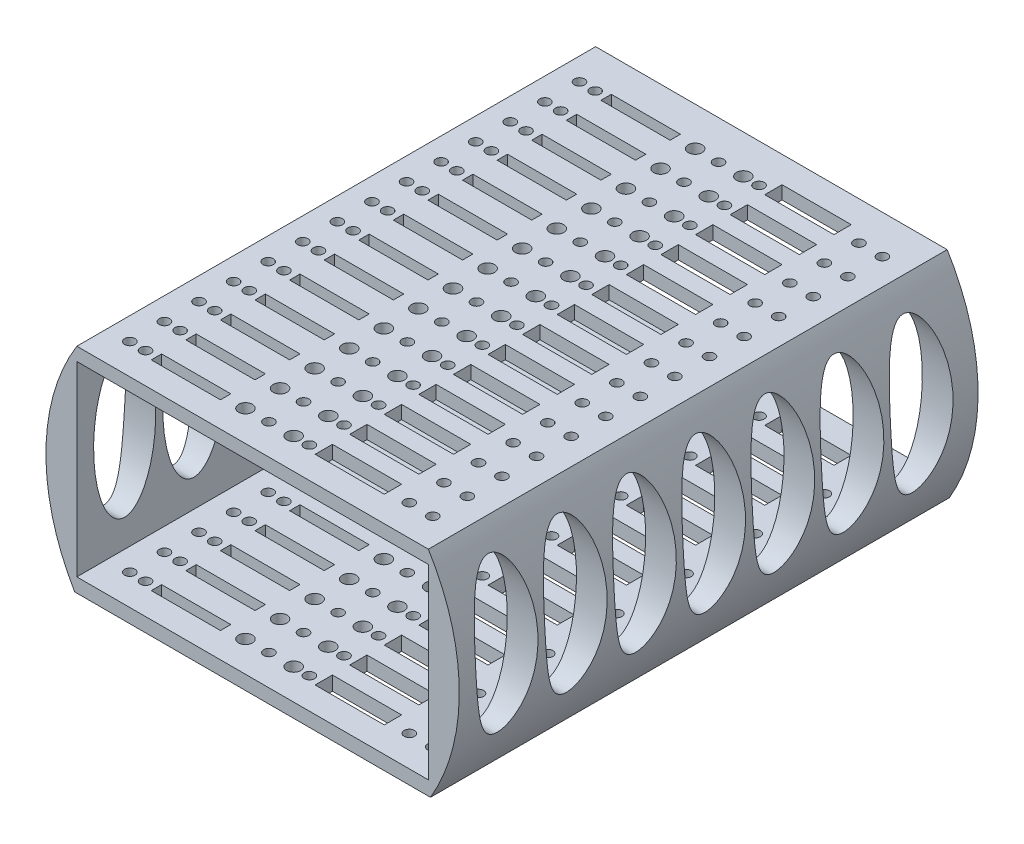
from build123d import *

# Parameters (mm, degrees)
SKETCH_4_R               = 59.75
EXTRUDE_1_DEPTH          = 150
CUT_EXTRUDE_3_DEPTH      = 173.163076762
CUT_EXTRUDE_3_DEPTH_BACK = 173.163076762
CUT_EXTRUDE_4_DEPTH      = 173.163076762
SKETCH_5_4_W             = 101.636218728
SKETCH_5_4_H             = 53.936134462
CUT_EXTRUDE_5_DEPTH      = 150
CUT_EXTRUDE_6_DEPTH      = 189.978541292
CUT_EXTRUDE_6_DEPTH_BACK = 189.978541292
SKETCH_6_RX              = 21.698109429
SKETCH_6_RY              = 8.98486276
CUT_EXTRUDE_7_DEPTH      = 173.897395707
CUT_EXTRUDE_7_DEPTH_BACK = 173.897395707
SKETCH_8_R               = 1.5
SKETCH_8_R_2             = 2
SKETCH_8_W               = 20
SKETCH_8_H               = 3
SKETCH_8_H_2             = 5


with BuildPart() as part:
    # 草图4 → 凸台-拉伸1 (new body)
    with BuildSketch(Plane.XY):
        Circle(SKETCH_4_R)
    extrude(amount=EXTRUDE_1_DEPTH)

    # 草图5 → 切除-拉伸3 (cut, two sides: drawn at the far end of the back side and taken through both)
    with BuildSketch(Plane.XY.offset(150).offset(-CUT_EXTRUDE_3_DEPTH_BACK)):
        with BuildLine():
            Line((-50.818109364, 31.425821559), (50.818109364, 31.425821559))
            ThreePointArc((50.818109364, 31.425821559), (0, 59.75), (-50.818109364, 31.425821559))
        make_face()
    extrude(amount=CUT_EXTRUDE_3_DEPTH + CUT_EXTRUDE_3_DEPTH_BACK, mode=Mode.SUBTRACT)

    # 草图5<3> → 切除-拉伸4 (cut, through all)
    with BuildSketch(Plane.XY.offset(150)):
        with BuildLine():
            Line((51.433486615, -30.408205384), (-51.433486615, -30.408205384))
            ThreePointArc((-51.433486615, -30.408205384), (0, -59.75), (51.433486615, -30.408205384))
        make_face()
    extrude(amount=-CUT_EXTRUDE_4_DEPTH, mode=Mode.SUBTRACT)

    # 草图5<4> → 切除-拉伸5 (cut)
    with BuildSketch(Plane.XY.offset(150)):
        with Locations((0, 0.631501799)):
            Rectangle(SKETCH_5_4_W, SKETCH_5_4_H)
    extrude(amount=-CUT_EXTRUDE_5_DEPTH, mode=Mode.SUBTRACT)

    # 草图6 → 切除-拉伸6 (cut, two sides: drawn at the far end of the back side and taken through both)
    with BuildSketch(Plane.ZY.offset(-50.818109364).offset(-CUT_EXTRUDE_6_DEPTH_BACK)):
        with Locations(Location((16.164235384, 3.394943947), (0, 0, -90))):
            Ellipse(SKETCH_6_RX, SKETCH_6_RY)
        with Locations(Location((36.164235384, 3.394943947), (0, 0, -90))):
            Ellipse(SKETCH_6_RX, SKETCH_6_RY)
        with Locations(Location((56.164235384, 3.394943947), (0, 0, -90))):
            Ellipse(SKETCH_6_RX, SKETCH_6_RY)
        with Locations(Location((76.164235384, 3.394943947), (0, 0, -90))):
            Ellipse(SKETCH_6_RX, SKETCH_6_RY)
        with Locations(Location((96.164235384, 3.394943947), (0, 0, -90))):
            Ellipse(SKETCH_6_RX, SKETCH_6_RY)
        with Locations(Location((116.164235384, 3.394943947), (0, 0, -90))):
            Ellipse(SKETCH_6_RX, SKETCH_6_RY)
        with Locations(Location((136.164235384, 3.394943947), (0, 0, -90))):
            Ellipse(SKETCH_6_RX, SKETCH_6_RY)
    extrude(amount=CUT_EXTRUDE_6_DEPTH + CUT_EXTRUDE_6_DEPTH_BACK, mode=Mode.SUBTRACT)

    # 草图8 → 切除-拉伸7 (cut, two sides: drawn at the far end of the back side and taken through both)
    with BuildSketch(Plane(origin=(0, 31.425821559, 0), x_dir=(1, 0, 0), z_dir=(0, 1, 0)).offset(-CUT_EXTRUDE_7_DEPTH_BACK)):
        with Locations((-44.320254624, -11.168496968)):
            Circle(SKETCH_8_R)
        with Locations((-39.784391217, -11.168496968)):
            Circle(SKETCH_8_R)
        with Locations((-10.889179801, -11.168496968)):
            Circle(SKETCH_8_R_2)
        with Locations((-4.106963021, -11.168496968)):
            Circle(SKETCH_8_R)
        with Locations((3.002209794, -11.117617248)):
            Circle(SKETCH_8_R_2)
        with Locations((7.538073201, -11.117617248)):
            Circle(SKETCH_8_R)
        with Locations((36.433284617, -11.117617248)):
            Circle(SKETCH_8_R)
        with Locations((43.215501397, -11.117617248)):
            Circle(SKETCH_8_R)
        with Locations((-44.320254624, -21.168496968)):
            Circle(SKETCH_8_R)
        with Locations((-39.784391217, -21.168496968)):
            Circle(SKETCH_8_R)
        with Locations((-10.889179801, -21.168496968)):
            Circle(SKETCH_8_R_2)
        with Locations((-4.106963021, -21.168496968)):
            Circle(SKETCH_8_R)
        with Locations((3.002209794, -21.117617248)):
            Circle(SKETCH_8_R_2)
        with Locations((7.538073201, -21.117617248)):
            Circle(SKETCH_8_R)
        with Locations((36.433284617, -21.117617248)):
            Circle(SKETCH_8_R)
        with Locations((43.215501397, -21.117617248)):
            Circle(SKETCH_8_R)
        with Locations((-44.320254624, -31.168496968)):
            Circle(SKETCH_8_R)
        with Locations((-39.784391217, -31.168496968)):
            Circle(SKETCH_8_R)
        with Locations((-10.889179801, -31.168496968)):
            Circle(SKETCH_8_R_2)
        with Locations((-4.106963021, -31.168496968)):
            Circle(SKETCH_8_R)
        with Locations((3.002209794, -31.117617248)):
            Circle(SKETCH_8_R_2)
        with Locations((7.538073201, -31.117617248)):
            Circle(SKETCH_8_R)
        with Locations((36.433284617, -31.117617248)):
            Circle(SKETCH_8_R)
        with Locations((43.215501397, -31.117617248)):
            Circle(SKETCH_8_R)
        with Locations((-44.320254624, -41.168496968)):
            Circle(SKETCH_8_R)
        with Locations((-39.784391217, -41.168496968)):
            Circle(SKETCH_8_R)
        with Locations((-10.889179801, -41.168496968)):
            Circle(SKETCH_8_R_2)
        with Locations((-4.106963021, -41.168496968)):
            Circle(SKETCH_8_R)
        with Locations((3.002209794, -41.117617248)):
            Circle(SKETCH_8_R_2)
        with Locations((7.538073201, -41.117617248)):
            Circle(SKETCH_8_R)
        with Locations((36.433284617, -41.117617248)):
            Circle(SKETCH_8_R)
        with Locations((43.215501397, -41.117617248)):
            Circle(SKETCH_8_R)
        with Locations((-44.320254624, -51.168496968)):
            Circle(SKETCH_8_R)
        with Locations((-39.784391217, -51.168496968)):
            Circle(SKETCH_8_R)
        with Locations((-10.889179801, -51.168496968)):
            Circle(SKETCH_8_R_2)
        with Locations((-4.106963021, -51.168496968)):
            Circle(SKETCH_8_R)
        with Locations((3.002209794, -51.117617248)):
            Circle(SKETCH_8_R_2)
        with Locations((7.538073201, -51.117617248)):
            Circle(SKETCH_8_R)
        with Locations((36.433284617, -51.117617248)):
            Circle(SKETCH_8_R)
        with Locations((43.215501397, -51.117617248)):
            Circle(SKETCH_8_R)
        with Locations((-44.320254624, -61.168496968)):
            Circle(SKETCH_8_R)
        with Locations((-39.784391217, -61.168496968)):
            Circle(SKETCH_8_R)
        with Locations((-10.889179801, -61.168496968)):
            Circle(SKETCH_8_R_2)
        with Locations((-4.106963021, -61.168496968)):
            Circle(SKETCH_8_R)
        with Locations((3.002209794, -61.117617248)):
            Circle(SKETCH_8_R_2)
        with Locations((7.538073201, -61.117617248)):
            Circle(SKETCH_8_R)
        with Locations((36.433284617, -61.117617248)):
            Circle(SKETCH_8_R)
        with Locations((43.215501397, -61.117617248)):
            Circle(SKETCH_8_R)
        with Locations((-44.320254624, -71.168496968)):
            Circle(SKETCH_8_R)
        with Locations((-39.784391217, -71.168496968)):
            Circle(SKETCH_8_R)
        with Locations((-10.889179801, -71.168496968)):
            Circle(SKETCH_8_R_2)
        with Locations((-4.106963021, -71.168496968)):
            Circle(SKETCH_8_R)
        with Locations((3.002209794, -71.117617248)):
            Circle(SKETCH_8_R_2)
        with Locations((7.538073201, -71.117617248)):
            Circle(SKETCH_8_R)
        with Locations((36.433284617, -71.117617248)):
            Circle(SKETCH_8_R)
        with Locations((43.215501397, -71.117617248)):
            Circle(SKETCH_8_R)
        with Locations((-44.320254624, -81.168496968)):
            Circle(SKETCH_8_R)
        with Locations((-39.784391217, -81.168496968)):
            Circle(SKETCH_8_R)
        with Locations((-10.889179801, -81.168496968)):
            Circle(SKETCH_8_R_2)
        with Locations((-4.106963021, -81.168496968)):
            Circle(SKETCH_8_R)
        with Locations((3.002209794, -81.117617248)):
            Circle(SKETCH_8_R_2)
        with Locations((7.538073201, -81.117617248)):
            Circle(SKETCH_8_R)
        with Locations((36.433284617, -81.117617248)):
            Circle(SKETCH_8_R)
        with Locations((43.215501397, -81.117617248)):
            Circle(SKETCH_8_R)
        with Locations((-44.320254624, -91.168496968)):
            Circle(SKETCH_8_R)
        with Locations((-39.784391217, -91.168496968)):
            Circle(SKETCH_8_R)
        with Locations((-10.889179801, -91.168496968)):
            Circle(SKETCH_8_R_2)
        with Locations((-4.106963021, -91.168496968)):
            Circle(SKETCH_8_R)
        with Locations((3.002209794, -91.117617248)):
            Circle(SKETCH_8_R_2)
        with Locations((7.538073201, -91.117617248)):
            Circle(SKETCH_8_R)
        with Locations((36.433284617, -91.117617248)):
            Circle(SKETCH_8_R)
        with Locations((43.215501397, -91.117617248)):
            Circle(SKETCH_8_R)
        with Locations((-44.320254624, -101.168496968)):
            Circle(SKETCH_8_R)
        with Locations((-39.784391217, -101.168496968)):
            Circle(SKETCH_8_R)
        with Locations((-10.889179801, -101.168496968)):
            Circle(SKETCH_8_R_2)
        with Locations((-4.106963021, -101.168496968)):
            Circle(SKETCH_8_R)
        with Locations((3.002209794, -101.117617248)):
            Circle(SKETCH_8_R_2)
        with Locations((7.538073201, -101.117617248)):
            Circle(SKETCH_8_R)
        with Locations((36.433284617, -101.117617248)):
            Circle(SKETCH_8_R)
        with Locations((43.215501397, -101.117617248)):
            Circle(SKETCH_8_R)
        with Locations((-44.320254624, -111.168496968)):
            Circle(SKETCH_8_R)
        with Locations((-39.784391217, -111.168496968)):
            Circle(SKETCH_8_R)
        with Locations((-10.889179801, -111.168496968)):
            Circle(SKETCH_8_R_2)
        with Locations((-4.106963021, -111.168496968)):
            Circle(SKETCH_8_R)
        with Locations((3.002209794, -111.117617248)):
            Circle(SKETCH_8_R_2)
        with Locations((7.538073201, -111.117617248)):
            Circle(SKETCH_8_R)
        with Locations((36.433284617, -111.117617248)):
            Circle(SKETCH_8_R)
        with Locations((43.215501397, -111.117617248)):
            Circle(SKETCH_8_R)
        with Locations((-44.320254624, -121.168496968)):
            Circle(SKETCH_8_R)
        with Locations((-39.784391217, -121.168496968)):
            Circle(SKETCH_8_R)
        with Locations((-10.889179801, -121.168496968)):
            Circle(SKETCH_8_R_2)
        with Locations((-4.106963021, -121.168496968)):
            Circle(SKETCH_8_R)
        with Locations((3.002209794, -121.117617248)):
            Circle(SKETCH_8_R_2)
        with Locations((7.538073201, -121.117617248)):
            Circle(SKETCH_8_R)
        with Locations((36.433284617, -121.117617248)):
            Circle(SKETCH_8_R)
        with Locations((43.215501397, -121.117617248)):
            Circle(SKETCH_8_R)
        with Locations((-44.320254624, -131.168496968)):
            Circle(SKETCH_8_R)
        with Locations((-39.784391217, -131.168496968)):
            Circle(SKETCH_8_R)
        with Locations((-10.889179801, -131.168496968)):
            Circle(SKETCH_8_R_2)
        with Locations((-4.106963021, -131.168496968)):
            Circle(SKETCH_8_R)
        with Locations((3.002209794, -131.117617248)):
            Circle(SKETCH_8_R_2)
        with Locations((7.538073201, -131.117617248)):
            Circle(SKETCH_8_R)
        with Locations((36.433284617, -131.117617248)):
            Circle(SKETCH_8_R)
        with Locations((43.215501397, -131.117617248)):
            Circle(SKETCH_8_R)
        with Locations((-44.320254624, -141.168496968)):
            Circle(SKETCH_8_R)
        with Locations((-39.784391217, -141.168496968)):
            Circle(SKETCH_8_R)
        with Locations((-10.889179801, -141.168496968)):
            Circle(SKETCH_8_R_2)
        with Locations((-4.106963021, -141.168496968)):
            Circle(SKETCH_8_R)
        with Locations((3.002209794, -141.117617248)):
            Circle(SKETCH_8_R_2)
        with Locations((7.538073201, -141.117617248)):
            Circle(SKETCH_8_R)
        with Locations((36.433284617, -141.117617248)):
            Circle(SKETCH_8_R)
        with Locations((43.215501397, -141.117617248)):
            Circle(SKETCH_8_R)
        with Locations((-26.630103352, -11.168496968)):
            Rectangle(SKETCH_8_W, SKETCH_8_H)
        with Locations((20.692361066, -10.117617248)):
            Rectangle(SKETCH_8_W, SKETCH_8_H_2)
        with Locations((-26.630103352, -21.168496968)):
            Rectangle(SKETCH_8_W, SKETCH_8_H)
        with Locations((20.692361066, -20.117617248)):
            Rectangle(SKETCH_8_W, SKETCH_8_H_2)
        with Locations((-26.630103352, -31.168496968)):
            Rectangle(SKETCH_8_W, SKETCH_8_H)
        with Locations((20.692361066, -30.117617248)):
            Rectangle(SKETCH_8_W, SKETCH_8_H_2)
        with Locations((-26.630103352, -41.168496968)):
            Rectangle(SKETCH_8_W, SKETCH_8_H)
        with Locations((20.692361066, -40.117617248)):
            Rectangle(SKETCH_8_W, SKETCH_8_H_2)
        with Locations((-26.630103352, -51.168496968)):
            Rectangle(SKETCH_8_W, SKETCH_8_H)
        with Locations((20.692361066, -50.117617248)):
            Rectangle(SKETCH_8_W, SKETCH_8_H_2)
        with Locations((-26.630103352, -61.168496968)):
            Rectangle(SKETCH_8_W, SKETCH_8_H)
        with Locations((20.692361066, -60.117617248)):
            Rectangle(SKETCH_8_W, SKETCH_8_H_2)
        with Locations((-26.630103352, -71.168496968)):
            Rectangle(SKETCH_8_W, SKETCH_8_H)
        with Locations((20.692361066, -70.117617248)):
            Rectangle(SKETCH_8_W, SKETCH_8_H_2)
        with Locations((-26.630103352, -81.168496968)):
            Rectangle(SKETCH_8_W, SKETCH_8_H)
        with Locations((20.692361066, -80.117617248)):
            Rectangle(SKETCH_8_W, SKETCH_8_H_2)
        with Locations((-26.630103352, -91.168496968)):
            Rectangle(SKETCH_8_W, SKETCH_8_H)
        with Locations((20.692361066, -90.117617248)):
            Rectangle(SKETCH_8_W, SKETCH_8_H_2)
        with Locations((-26.630103352, -101.168496968)):
            Rectangle(SKETCH_8_W, SKETCH_8_H)
        with Locations((20.692361066, -100.117617248)):
            Rectangle(SKETCH_8_W, SKETCH_8_H_2)
        with Locations((-26.630103352, -111.168496968)):
            Rectangle(SKETCH_8_W, SKETCH_8_H)
        with Locations((20.692361066, -110.117617248)):
            Rectangle(SKETCH_8_W, SKETCH_8_H_2)
        with Locations((-26.630103352, -121.168496968)):
            Rectangle(SKETCH_8_W, SKETCH_8_H)
        with Locations((20.692361066, -120.117617248)):
            Rectangle(SKETCH_8_W, SKETCH_8_H_2)
        with Locations((-26.630103352, -131.168496968)):
            Rectangle(SKETCH_8_W, SKETCH_8_H)
        with Locations((20.692361066, -130.117617248)):
            Rectangle(SKETCH_8_W, SKETCH_8_H_2)
        with Locations((-26.630103352, -141.168496968)):
            Rectangle(SKETCH_8_W, SKETCH_8_H)
        with Locations((20.692361066, -140.117617248)):
            Rectangle(SKETCH_8_W, SKETCH_8_H_2)
    extrude(amount=CUT_EXTRUDE_7_DEPTH + CUT_EXTRUDE_7_DEPTH_BACK, mode=Mode.SUBTRACT)


solid = part.part
